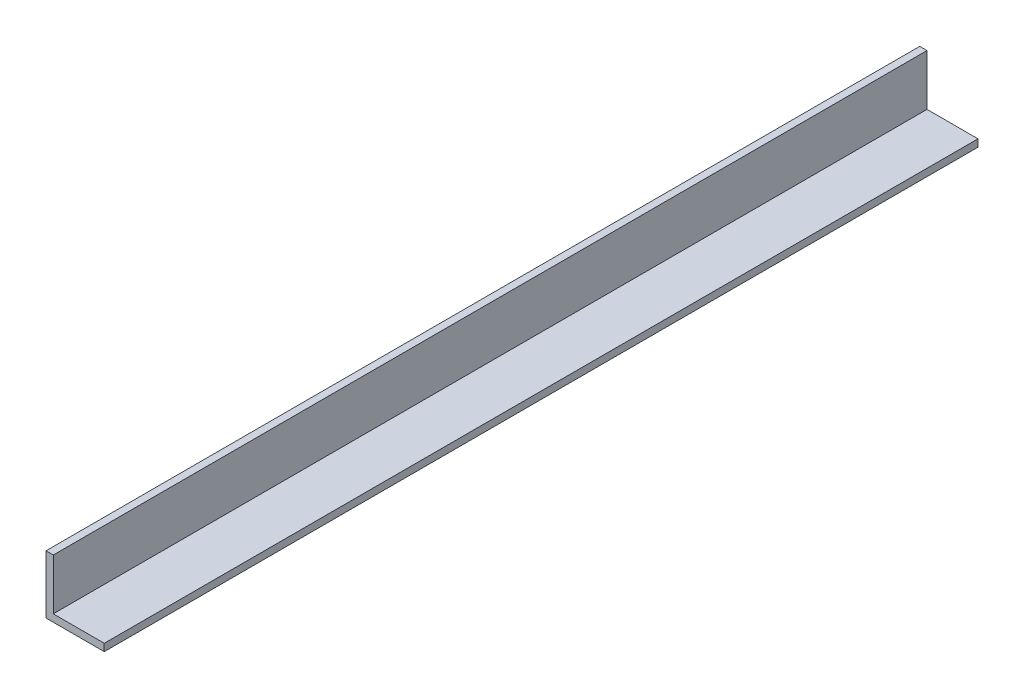
from build123d import *

# Parameters (mm, degrees)
BOSS_EXTRUDE1_DEPTH = 381


with BuildPart() as part:
    # Sketch1 → Boss-Extrude1 (new body)
    with BuildSketch(Plane.XY):
        Polygon((0, 0), (25.4, 0), (25.4, 3.175), (3.175, 3.175), (3.175, 25.4), (0, 25.4), align=None)
    extrude(amount=BOSS_EXTRUDE1_DEPTH)


solid = part.part
